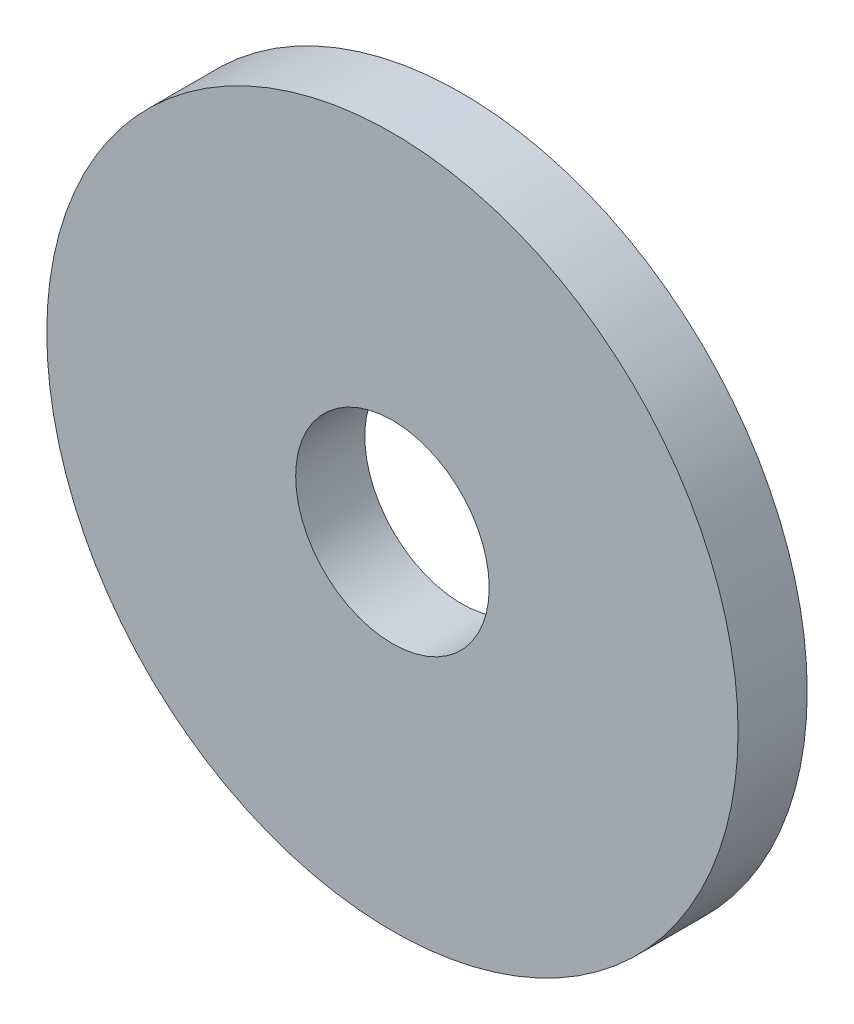
from build123d import *

# Parameters (mm, degrees)
SKETCH1_R               = 19.05
SKETCH1_R_2             = 8.001
BOSS_EXTRUDE1_DEPTH     = 3.175
SKETCH2_R               = 19.05
BOSS_EXTRUDE2_DEPTH     = 4.7625
F_3_8_CLEARANCE_HOLE1_D = 10.31748
SKETCH6_R               = 8.001
CUT_EXTRUDE1_DEPTH      = 2.54
SKETCH7_R               = 19.05
CUT_EXTRUDE2_DEPTH      = 2.2225
SKETCH8_R               = 28.575
SKETCH8_R_2             = 19.05
BOSS_EXTRUDE3_DEPTH     = 5.715


with BuildPart() as part:
    # Sketch1 → Boss-Extrude1 (new body)
    with BuildSketch(Plane.XY):
        with Locations((95.864074702, 45.465579041)):
            Circle(SKETCH1_R)
        with Locations((95.864074702, 45.465579041)):
            Circle(SKETCH1_R_2, mode=Mode.SUBTRACT)
    extrude(amount=-BOSS_EXTRUDE1_DEPTH)

    # Sketch2 → Boss-Extrude2 (add)
    with BuildSketch(Plane.XY):
        with Locations((95.864074702, 45.465579041)):
            Circle(SKETCH2_R)
    extrude(amount=BOSS_EXTRUDE2_DEPTH)

    # 3/8 Clearance Hole1 (through all)
    with Locations(Plane.XY.offset(4.7625)):
        with Locations((95.864074702, 45.465579041)):
            Hole(F_3_8_CLEARANCE_HOLE1_D / 2)

    # Sketch6 → Cut-Extrude1 (cut)
    with BuildSketch(Plane(origin=(0, 0, 0), x_dir=(-1, 0, 0), z_dir=(0, 0, -1))):
        with Locations((-95.864074702, 45.465579041)):
            Circle(SKETCH6_R)
    extrude(amount=-CUT_EXTRUDE1_DEPTH, mode=Mode.SUBTRACT)

    # Sketch7 → Cut-Extrude2 (cut)
    with BuildSketch(Plane.XY.offset(4.7625)):
        with Locations((95.864074702, 45.465579041)):
            Circle(SKETCH7_R)
    extrude(amount=-CUT_EXTRUDE2_DEPTH, mode=Mode.SUBTRACT)

    # Sketch8 → Boss-Extrude3 (add)
    with BuildSketch(Plane(origin=(0, 0, -3.175), x_dir=(-1, 0, 0), z_dir=(0, 0, -1))):
        with Locations((-95.864074702, 45.465579041)):
            Circle(SKETCH8_R)
        with Locations((-95.864074702, 45.465579041)):
            Circle(SKETCH8_R_2, mode=Mode.SUBTRACT)
    extrude(amount=-BOSS_EXTRUDE3_DEPTH)


solid = part.part
